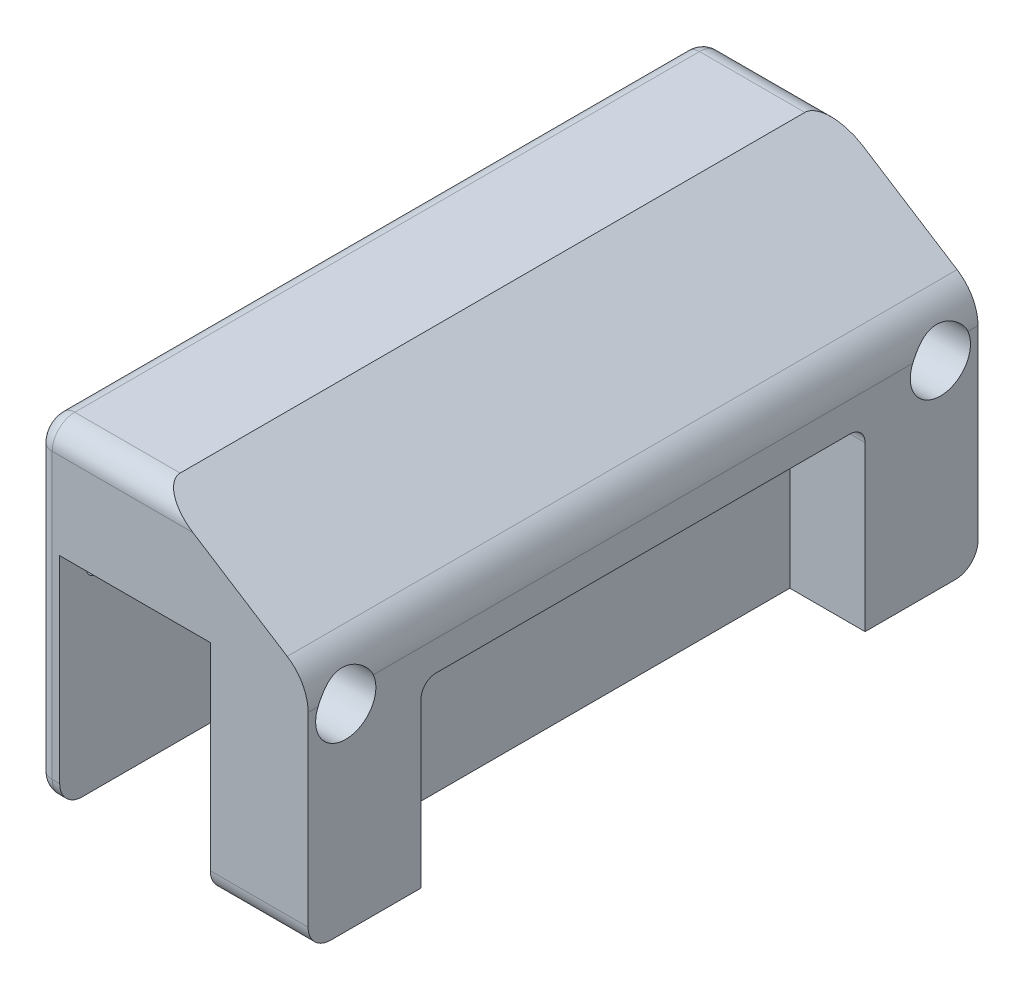
from build123d import *

# Parameters (mm, degrees)
RESSALTO_EXTRUS_O2_DEPTH      = 30
RESSALTO_EXTRUS_O3_DEPTH      = 3
RESSALTO_EXTRUS_O4_DEPTH      = 3
RESSALTO_EXTRUS_O4_DEPTH_BACK = 10
CORTE_EXTRUS_O1_DEPTH         = 10
CORTE_EXTRUS_O2_DEPTH         = 23.75
ESBO_O10_R                    = 1.5
CORTE_EXTRUS_O3_DEPTH         = 10
CORTE_EXTRUS_O4_DEPTH         = 10
FILETE2_R                     = 2
ESBO_O13_R                    = 1.5
CORTE_EXTRUS_O5_DEPTH         = 16
CORTE_EXTRUS_O11_DEPTH        = 117
FILETE7_R                     = 6
ESBO_O18_R                    = 4
CORTE_EXTRUS_O13_DEPTH        = 22
ESBO_O19_R                    = 4
CORTE_EXTRUS_O14_DEPTH        = 22


with BuildPart() as part:
    # Esboço2 → Ressalto-extrusão2 (new body)
    with BuildSketch(Plane(origin=(0, 0, 0), x_dir=(0, 0, -1), z_dir=(1, 0, 0))):
        with BuildLine():
            Line((2.90159992, -0.062465938), (-35.09840008, -0.062465938))
            Line((-35.09840008, -0.062465938), (-39.886084903, -0.062465938))
            ThreePointArc((-39.886084903, -0.062465938), (-45.202180234, 1.467638524), (-48.891439328, 5.589707975))
            ThreePointArc((-48.891439328, 5.589707975), (-52.096536948, 9.772081499), (-56.69840008, 12.338743681))
            ThreePointArc((-56.69840008, 12.338743681), (-59.373224015, 11.895603401), (-60.59840008, 9.476926077))
            Line((-60.59840008, 9.476926077), (-60.59840008, 20.976926077))
            ThreePointArc((-60.59840008, 20.976926077), (-59.719720424, 23.09824642), (-57.59840008, 23.976926077))
            Line((-57.59840008, 23.976926077), (25.40159992, 23.976926077))
            ThreePointArc((25.40159992, 23.976926077), (27.522920263, 23.09824642), (28.40159992, 20.976926077))
            Line((28.40159992, 20.976926077), (28.40159992, 9.476926077))
            ThreePointArc((28.40159992, 9.476926077), (27.176423855, 11.895603401), (24.50159992, 12.338743681))
            ThreePointArc((24.50159992, 12.338743681), (19.899736788, 9.772081499), (16.694639168, 5.589707975))
            ThreePointArc((16.694639168, 5.589707975), (13.005380073, 1.467638524), (7.689284743, -0.062465938))
            Line((7.689284743, -0.062465938), (2.90159992, -0.062465938))
        make_face()
    extrude(amount=RESSALTO_EXTRUS_O2_DEPTH)

    # Esboço3 → Ressalto-extrusão3 (add)
    with BuildSketch(Plane.ZY):
        with BuildLine():
            Line((60.59840008, 15.226926077), (60.59840008, 20.976926077))
            ThreePointArc((60.59840008, 20.976926077), (59.719720424, 23.09824642), (57.59840008, 23.976926077))
            Line((57.59840008, 23.976926077), (16.09840008, 23.976926077))
            Line((16.09840008, 23.976926077), (-25.40159992, 23.976926077))
            ThreePointArc((-25.40159992, 23.976926077), (-27.522920263, 23.09824642), (-28.40159992, 20.976926077))
            Line((-28.40159992, 20.976926077), (-28.40159992, 15.226926077))
            Line((-28.40159992, 15.226926077), (-28.40159992, -16.773073923))
            ThreePointArc((-28.40159992, -16.773073923), (-27.522920263, -18.894394267), (-25.40159992, -19.773073923))
            Line((-25.40159992, -19.773073923), (57.59840008, -19.773073923))
            ThreePointArc((57.59840008, -19.773073923), (59.719720424, -18.894394267), (60.59840008, -16.773073923))
            Line((60.59840008, -16.773073923), (60.59840008, 15.226926077))
        make_face()
    extrude(amount=RESSALTO_EXTRUS_O3_DEPTH)

    # Esboço4 → Ressalto-extrusão4 (add, two sides)
    with BuildSketch(Plane(origin=(30, 0, 0), x_dir=(0, 0, -1), z_dir=(1, 0, 0))) as ressalto_extrus_o4_sk:
        with BuildLine():
            Line((-16.09840008, 23.976926077), (25.40159992, 23.976926077))
            ThreePointArc((25.40159992, 23.976926077), (27.522920263, 23.09824642), (28.40159992, 20.976926077))
            Line((28.40159992, 20.976926077), (28.40159992, 15.226926077))
            Line((28.40159992, 15.226926077), (28.40159992, -16.773073923))
            ThreePointArc((28.40159992, -16.773073923), (27.522920263, -18.894394267), (25.40159992, -19.773073923))
            Line((25.40159992, -19.773073923), (-57.59840008, -19.773073923))
            ThreePointArc((-57.59840008, -19.773073923), (-59.719720424, -18.894394267), (-60.59840008, -16.773073923))
            Line((-60.59840008, -16.773073923), (-60.59840008, 15.226926077))
            Line((-60.59840008, 15.226926077), (-60.59840008, 20.976926077))
            ThreePointArc((-60.59840008, 20.976926077), (-59.719720424, 23.09824642), (-57.59840008, 23.976926077))
            Line((-57.59840008, 23.976926077), (-16.09840008, 23.976926077))
        make_face()
    extrude(amount=RESSALTO_EXTRUS_O4_DEPTH)
    extrude(ressalto_extrus_o4_sk.sketch, amount=-RESSALTO_EXTRUS_O4_DEPTH_BACK)

    # Esboço8 → Corte-extrusão1 (cut)
    with BuildSketch(Plane(origin=(33, 0, 0), x_dir=(0, 0, -1), z_dir=(1, 0, 0))):
        with BuildLine():
            Line((-43.59840008, 3.976926077), (11.40159992, 3.976926077))
            ThreePointArc((11.40159992, 3.976926077), (12.815813482, 3.391139639), (13.40159992, 1.976926077))
            Line((13.40159992, 1.976926077), (13.40159992, -7.773073923))
            Line((13.40159992, -7.773073923), (13.40159992, -19.773073923))
            Line((13.40159992, -19.773073923), (-45.59840008, -19.773073923))
            Line((-45.59840008, -19.773073923), (-45.59840008, -7.773073923))
            Line((-45.59840008, -7.773073923), (-45.59840008, 1.976926077))
            ThreePointArc((-45.59840008, 1.976926077), (-45.012613643, 3.391139639), (-43.59840008, 3.976926077))
        make_face()
    extrude(amount=-CORTE_EXTRUS_O1_DEPTH, mode=Mode.SUBTRACT)

    # Esboço9 → Corte-extrusão2 (cut)
    with BuildSketch(Plane(origin=(0, -19.773073923, 0), x_dir=(-1, 0, 0), z_dir=(0, -1, 0))):
        with BuildLine():
            Line((-25, 13.40159992), (-28, 13.40159992))
            ThreePointArc((-28, 13.40159992), (-29.414213562, 12.815813482), (-30, 11.40159992))
            Line((-30, 11.40159992), (-30, -43.59840008))
            ThreePointArc((-30, -43.59840008), (-29.414213562, -45.012613643), (-28, -45.59840008))
            Line((-28, -45.59840008), (-25, -45.59840008))
            ThreePointArc((-25, -45.59840008), (-23.585786438, -45.012613643), (-23, -43.59840008))
            Line((-23, -43.59840008), (-23, 11.40159992))
            ThreePointArc((-23, 11.40159992), (-23.585786438, 12.815813482), (-25, 13.40159992))
        make_face()
    extrude(amount=-CORTE_EXTRUS_O2_DEPTH, mode=Mode.SUBTRACT)

    # Esboço10 → Corte-extrusão3 (cut)
    with BuildSketch(Plane(origin=(0, 0, 0), x_dir=(0, 0, -1), z_dir=(1, 0, 0))):
        with Locations((-55.59840008, 6.338743681)):
            Circle(ESBO_O10_R)
        with Locations((23.40159992, 6.338743681)):
            Circle(ESBO_O10_R)
        with Locations((-16.09840008, -8.562465938)):
            Circle(ESBO_O10_R)
    extrude(amount=-CORTE_EXTRUS_O3_DEPTH, mode=Mode.SUBTRACT)

    # Esboço12 → Corte-extrusão4 (cut)
    with BuildSketch(Plane(origin=(0, 0, 0), x_dir=(0, 0, -1), z_dir=(1, 0, 0))):
        with BuildLine():
            Line((-31.59840008, -2.862465938), (-25.59840008, -2.862465938))
            ThreePointArc((-25.59840008, -2.862465938), (-24.184186518, -3.448252375), (-23.59840008, -4.862465938))
            Line((-23.59840008, -4.862465938), (-23.59840008, -14.773073923))
            ThreePointArc((-23.59840008, -14.773073923), (-24.184186518, -16.187287486), (-25.59840008, -16.773073923))
            Line((-25.59840008, -16.773073923), (-31.59840008, -16.773073923))
            ThreePointArc((-31.59840008, -16.773073923), (-33.012613643, -16.187287486), (-33.59840008, -14.773073923))
            Line((-33.59840008, -14.773073923), (-33.59840008, -4.862465938))
            ThreePointArc((-33.59840008, -4.862465938), (-33.012613643, -3.448252375), (-31.59840008, -2.862465938))
        make_face()
        with BuildLine():
            Line((-6.59840008, -2.862465938), (-0.59840008, -2.862465938))
            ThreePointArc((-0.59840008, -2.862465938), (0.815813482, -3.448252375), (1.40159992, -4.862465938))
            Line((1.40159992, -4.862465938), (1.40159992, -14.773073923))
            ThreePointArc((1.40159992, -14.773073923), (0.815813482, -16.187287486), (-0.59840008, -16.773073923))
            Line((-0.59840008, -16.773073923), (-6.59840008, -16.773073923))
            ThreePointArc((-6.59840008, -16.773073923), (-8.012613643, -16.187287486), (-8.59840008, -14.773073923))
            Line((-8.59840008, -14.773073923), (-8.59840008, -4.862465938))
            ThreePointArc((-8.59840008, -4.862465938), (-8.012613643, -3.448252375), (-6.59840008, -2.862465938))
        make_face()
    extrude(amount=-CORTE_EXTRUS_O4_DEPTH, mode=Mode.SUBTRACT)

    # Filete2
    filete2_edges = [part.edges().sort_by_distance(p)[0] for p in [
        (-3, 2.101926077, 60.59840008),
        (-3, 23.09824642, 59.719720424),
        (-3, 23.976926077, 16.09840008),
        (-3, 23.09824642, -27.522920263),
        (-3, 2.101926077, -28.40159992),
        (-3, -18.894394267, -27.522920263),
        (-3, -19.773073923, 16.09840008),
        (-3, -18.894394267, 59.719720424),
    ]]
    fillet(filete2_edges, radius=FILETE2_R)

    # Esboço13 → Corte-extrusão5 (cut)
    with BuildSketch(Plane.ZY.offset(3)):
        with Locations((27.44840008, 3.976926077)):
            Circle(ESBO_O13_R)
        with Locations((4.74840008, 3.976926077)):
            Circle(ESBO_O13_R)
    extrude(amount=-CORTE_EXTRUS_O5_DEPTH, mode=Mode.SUBTRACT)

    # Esboço16 → Corte-extrusão11 (cut)
    with BuildSketch(Plane(origin=(0, 0, -38.40159992), x_dir=(-1, 0, 0), z_dir=(0, 0, -1))):
        Polygon((-13, 23.976926077), (-33, 11.226201247), (-33, 23.976926077), align=None)
    extrude(amount=-CORTE_EXTRUS_O11_DEPTH, mode=Mode.SUBTRACT)

    # Filete7
    filete7_edges = [part.edges().sort_by_distance(p)[0] for p in [
        (33, 11.226201247, 16.09840008),
    ]]
    fillet(filete7_edges, radius=FILETE7_R)

    # Esboço18 → Corte-extrusão13 (cut)
    with BuildSketch(Plane.ZY.offset(-20)):
        with Locations((-23.40159992, 6.338743681)):
            Circle(ESBO_O18_R)
    extrude(amount=-CORTE_EXTRUS_O13_DEPTH, mode=Mode.SUBTRACT)

    # Esboço19 → Corte-extrusão14 (cut)
    with BuildSketch(Plane.ZY.offset(-20)):
        with Locations((55.59840008, 6.338743681)):
            Circle(ESBO_O19_R)
    extrude(amount=-CORTE_EXTRUS_O14_DEPTH, mode=Mode.SUBTRACT)


solid = part.part
